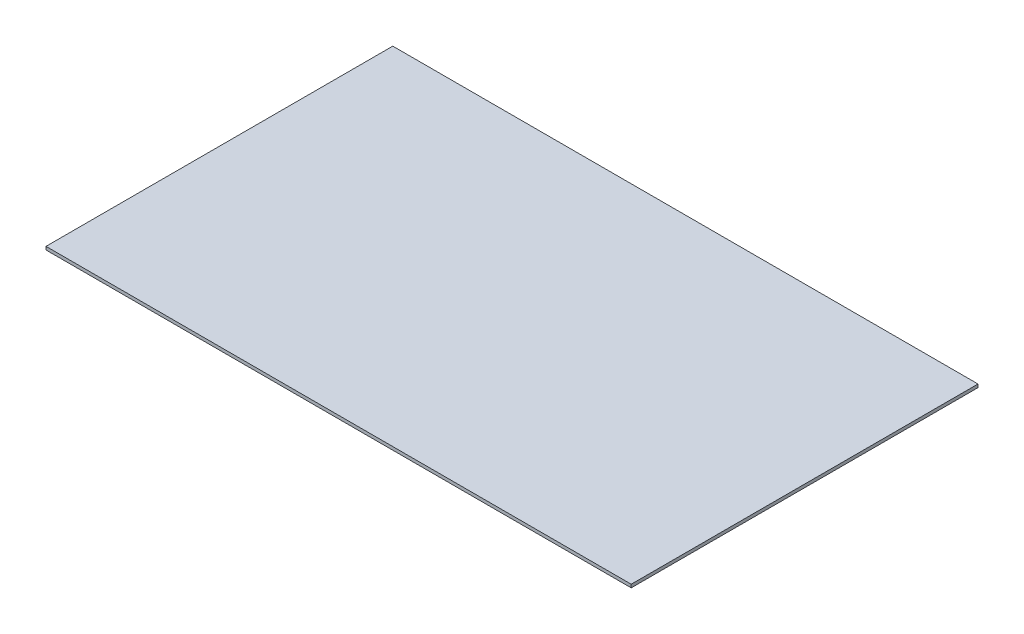
from build123d import *

# Parameters (mm, degrees)
SKETCH1_W           = 514.35
SKETCH1_H           = 304.8
BOSS_EXTRUDE1_DEPTH = 2.794


with BuildPart() as part:
    # Sketch1 → Boss-Extrude1 (new body)
    with BuildSketch(Plane(origin=(0, 0, 0), x_dir=(1, 0, 0), z_dir=(0, 1, 0))):
        with Locations((257.175, 152.4)):
            Rectangle(SKETCH1_W, SKETCH1_H)
    extrude(amount=BOSS_EXTRUDE1_DEPTH)


solid = part.part
